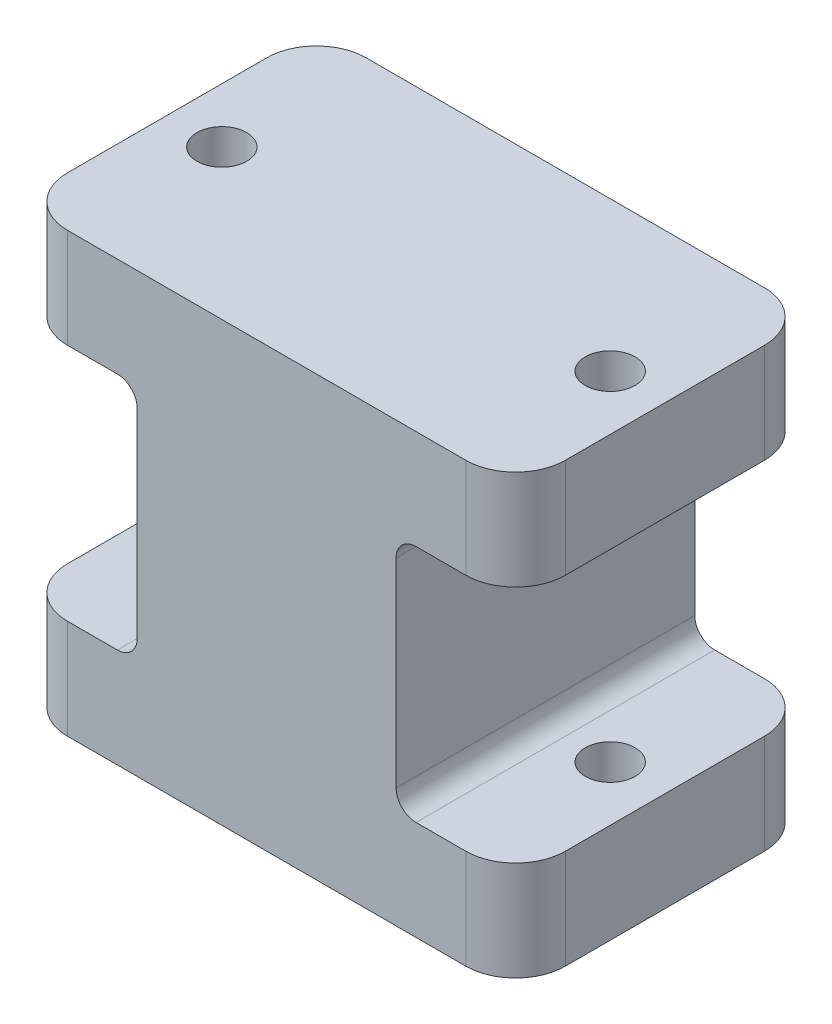
from build123d import *

# Parameters (mm, degrees)
SKETCH1_R           = 2.5
BOSS_EXTRUDE1_DEPTH = 44
SKETCH2_W           = 30
SKETCH2_H           = 24
CUT_EXTRUDE1_DEPTH  = 12
FILLET1_R           = 2


with BuildPart() as part:
    # Sketch1 → Boss-Extrude1 (new body)
    with BuildSketch(Plane(origin=(0, 0, 0), x_dir=(1, 0, 0), z_dir=(0, 1, 0))):
        with BuildLine():
            Line((20, -15), (-20, -15))
            ThreePointArc((-20, -15), (-23.535533906, -13.535533906), (-25, -10))
            Line((-25, -10), (-25, 10))
            ThreePointArc((-25, 10), (-23.535533906, 13.535533906), (-20, 15))
            Line((-20, 15), (20, 15))
            ThreePointArc((20, 15), (23.535533906, 13.535533906), (25, 10))
            Line((25, 10), (25, -10))
            ThreePointArc((25, -10), (23.535533906, -13.535533906), (20, -15))
        make_face()
        with Locations((-19.5, 0)):
            Circle(SKETCH1_R, mode=Mode.SUBTRACT)
        with Locations((19.5, 0)):
            Circle(SKETCH1_R, mode=Mode.SUBTRACT)
    extrude(amount=BOSS_EXTRUDE1_DEPTH)

    # Sketch2 → Cut-Extrude1 (cut)
    with BuildSketch(Plane.ZY.offset(25)):
        with Locations((0, 22)):
            Rectangle(SKETCH2_W, SKETCH2_H)
    cut_extrude1 = extrude(amount=-CUT_EXTRUDE1_DEPTH, mode=Mode.SUBTRACT)

    # Mirror1: Cut-Extrude1 across plane
    add(cut_extrude1.mirror(Plane(origin=(0, 0, 0), x_dir=(0, 0, 1), z_dir=(1, 0, 0))), mode=Mode.SUBTRACT)

    # Fillet1
    fillet1_edges = [part.edges().sort_by_distance(p)[0] for p in [
        (-13, 34, 0),
        (-13, 10, 0),
        (13, 10, 0),
        (13, 34, 0),
    ]]
    fillet(fillet1_edges, radius=FILLET1_R)


solid = part.part
